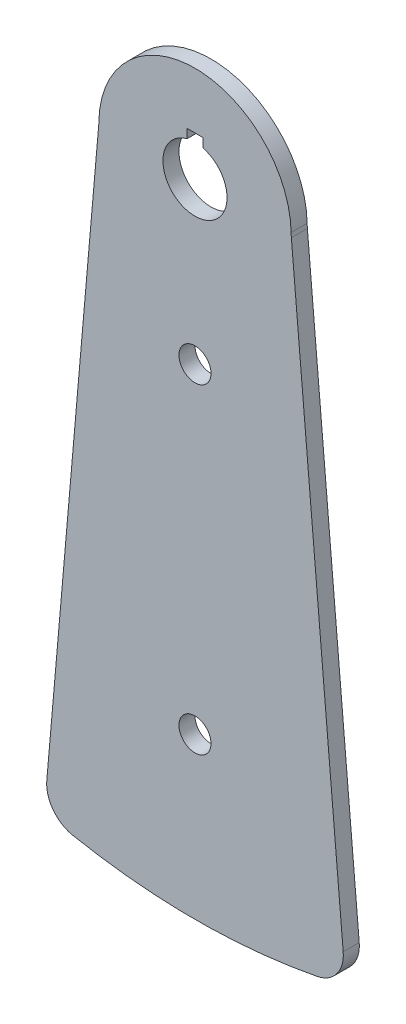
from build123d import *

# Parameters (mm, degrees)
SKETCH1_R               = 12.7
BOSS_EXTRUDE1_DEPTH     = 3.175
SKETCH8_W               = 6.35
SKETCH8_H               = 6.35
CUT_EXTRUDE1_DEPTH      = 4.175
CUT_EXTRUDE1_DEPTH_BACK = 4.175
SKETCH9_R               = 6.35
CUT_EXTRUDE2_DEPTH      = 4.175
CUT_EXTRUDE2_DEPTH_BACK = 4.175
FILLET1_R               = 12.7


with BuildPart() as part:
    # Sketch1 → Boss-Extrude1 (new body, symmetric)
    with BuildSketch(Plane.XY):
        with BuildLine():
            Line((-59.699595301, -246.884504011), (-38.184359795, -0.964236874))
            ThreePointArc((-38.184359795, -0.964236874), (-38.124009824, -0.108037848), (-38.092623076, 0.749711395))
            ThreePointArc((-38.092623076, 0.749711395), (0, 38.1), (38.092623076, 0.749711395))
            ThreePointArc((38.092623076, 0.749711395), (38.124009824, -0.108037848), (38.184359795, -0.964236874))
            Line((38.184359795, -0.964236874), (59.699595301, -246.884504011))
            ThreePointArc((59.699595301, -246.884504011), (0, -254), (-59.699595301, -246.884504011))
        make_face()
        Circle(SKETCH1_R, mode=Mode.SUBTRACT)
    extrude(amount=BOSS_EXTRUDE1_DEPTH, both=True)

    # Sketch8 → Cut-Extrude1 (cut, two sides)
    with BuildSketch(Plane.XY) as cut_extrude1_sk:
        with Locations((0, 12.7)):
            Rectangle(SKETCH8_W, SKETCH8_H)
    extrude(amount=CUT_EXTRUDE1_DEPTH, mode=Mode.SUBTRACT)
    extrude(cut_extrude1_sk.sketch, amount=-CUT_EXTRUDE1_DEPTH_BACK, mode=Mode.SUBTRACT)

    # Sketch9 → Cut-Extrude2 (cut, two sides)
    with BuildSketch(Plane.XY) as cut_extrude2_sk:
        with Locations((0, -63.5)):
            Circle(SKETCH9_R)
        with Locations((0, -190.5)):
            Circle(SKETCH9_R)
    extrude(amount=CUT_EXTRUDE2_DEPTH, mode=Mode.SUBTRACT)
    extrude(cut_extrude2_sk.sketch, amount=-CUT_EXTRUDE2_DEPTH_BACK, mode=Mode.SUBTRACT)

    # Fillet1
    fillet1_edges = [part.edges().sort_by_distance(p)[0] for p in [
        (-59.699595301, -246.884504011, 0),
        (59.699595301, -246.884504011, 0),
    ]]
    fillet(fillet1_edges, radius=FILLET1_R)


solid = part.part
